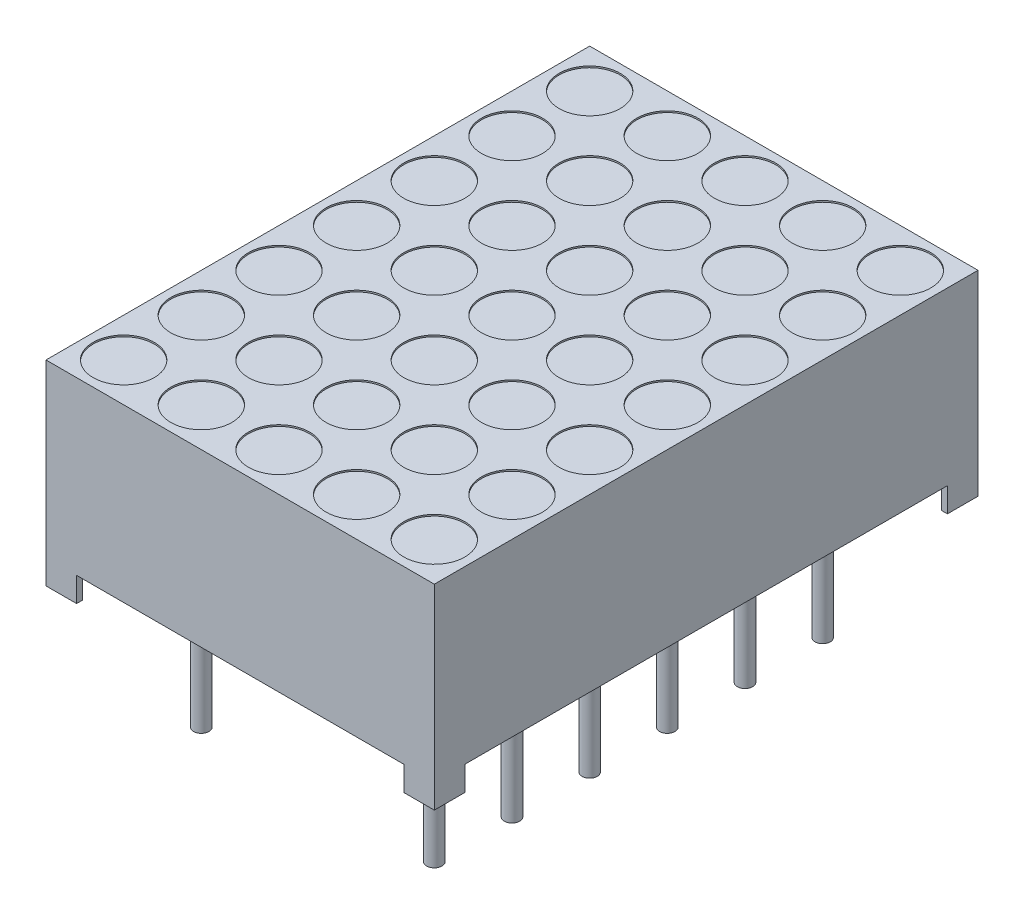
from build123d import *

# Parameters (mm, degrees)
EXTRUDE1_DEPTH     = 6.35
SKETCH3_W          = 10.7
SKETCH3_H          = 0.8
CUT_EXTRUDE1_DEPTH = 18.78
SKETCH2_R          = 1
CUT_EXTRUDE2_DEPTH = 0.05
SKETCH4_R          = 0.25
EXTRUDE2_DEPTH     = 0.8
SKETCH4_3_R        = 0.25
EXTRUDE3_DEPTH     = 4
SKETCH4_4_W        = 0.8
SKETCH4_4_H        = 0.8
CUT_EXTRUDE3_DEPTH = 0.8
SKETCH5_W          = 0.025316456
SKETCH5_H          = 0.026582278
CUT_EXTRUDE4_DEPTH = 0.01


with BuildPart() as part:
    # Sketch1 → Extrude1 (new body, symmetric)
    with BuildSketch(Plane(origin=(0, 0, 0), x_dir=(0, 0, -1), z_dir=(1, 0, 0))):
        Polygon((8.89, 3.2), (-8.89, 3.2), (6.6675, -2.4), (7.89, -2.4), (7.89, -2.840044994), (8.89, -3.2), align=None)
        Polygon((6.6675, -2.4), (-8.89, 3.2), (-8.89, -3.2), (-7.89, -3.2), (-7.89, -2.4), align=None)
        Polygon((8.89, -3.2), (7.89, -2.840044994), (7.89, -3.2), align=None)
    extrude(amount=EXTRUDE1_DEPTH, both=True)

    # Sketch3 → Cut-Extrude1 (cut, through all)
    with BuildSketch(Plane.XY.offset(8.89)):
        with Locations((0, -2.8)):
            Rectangle(SKETCH3_W, SKETCH3_H)
    extrude(amount=-CUT_EXTRUDE1_DEPTH, mode=Mode.SUBTRACT)

    # Sketch2 → Cut-Extrude2 (cut)
    with BuildSketch(Plane(origin=(0, 3.2, 0), x_dir=(-1, 0, 0), z_dir=(0, 1, 0))):
        with Locations(Location((5.08, -7.62, 0), (0, 0, 90))):  # turned: the seam where the file's is
            Circle(SKETCH2_R)
        with Locations(Location((2.54, -7.62, 0), (0, 0, 90))):  # turned: the seam where the file's is
            Circle(SKETCH2_R)
        with Locations(Location((0, -7.62, 0), (0, 0, 90))):  # turned: the seam where the file's is
            Circle(SKETCH2_R)
        with Locations(Location((-2.54, -7.62, 0), (0, 0, 90))):  # turned: the seam where the file's is
            Circle(SKETCH2_R)
        with Locations(Location((-5.08, -7.62, 0), (0, 0, 90))):  # turned: the seam where the file's is
            Circle(SKETCH2_R)
        with Locations(Location((-5.08, -5.08, 0), (0, 0, 90))):  # turned: the seam where the file's is
            Circle(SKETCH2_R)
        with Locations(Location((-2.54, -5.08, 0), (0, 0, 90))):  # turned: the seam where the file's is
            Circle(SKETCH2_R)
        with Locations(Location((0, -5.08, 0), (0, 0, 90))):  # turned: the seam where the file's is
            Circle(SKETCH2_R)
        with Locations(Location((2.54, -5.08, 0), (0, 0, 90))):  # turned: the seam where the file's is
            Circle(SKETCH2_R)
        with Locations(Location((5.08, -5.08, 0), (0, 0, 90))):  # turned: the seam where the file's is
            Circle(SKETCH2_R)
        with Locations(Location((5.08, -2.54, 0), (0, 0, 90))):  # turned: the seam where the file's is
            Circle(SKETCH2_R)
        with Locations(Location((2.54, -2.54, 0), (0, 0, 90))):  # turned: the seam where the file's is
            Circle(SKETCH2_R)
        with Locations(Location((0, -2.54, 0), (0, 0, 90))):  # turned: the seam where the file's is
            Circle(SKETCH2_R)
        with Locations(Location((-2.54, -2.54, 0), (0, 0, 90))):  # turned: the seam where the file's is
            Circle(SKETCH2_R)
        with Locations(Location((-5.08, -2.54, 0), (0, 0, 90))):  # turned: the seam where the file's is
            Circle(SKETCH2_R)
        with Locations(Location((-5.08, 0, 0), (0, 0, 90))):  # turned: the seam where the file's is
            Circle(SKETCH2_R)
        with Locations(Location((-2.54, 0, 0), (0, 0, 90))):  # turned: the seam where the file's is
            Circle(SKETCH2_R)
        with Locations(Location((0, 0, 0), (0, 0, 90))):  # turned: the seam where the file's is
            Circle(SKETCH2_R)
        with Locations(Location((2.54, 0, 0), (0, 0, 90))):  # turned: the seam where the file's is
            Circle(SKETCH2_R)
        with Locations(Location((5.08, 0, 0), (0, 0, 90))):  # turned: the seam where the file's is
            Circle(SKETCH2_R)
        with Locations(Location((5.08, 2.54, 0), (0, 0, 90))):  # turned: the seam where the file's is
            Circle(SKETCH2_R)
        with Locations(Location((2.54, 2.54, 0), (0, 0, 90))):  # turned: the seam where the file's is
            Circle(SKETCH2_R)
        with Locations(Location((0, 2.54, 0), (0, 0, 90))):  # turned: the seam where the file's is
            Circle(SKETCH2_R)
        with Locations(Location((-2.54, 2.54, 0), (0, 0, 90))):  # turned: the seam where the file's is
            Circle(SKETCH2_R)
        with Locations(Location((-5.08, 2.54, 0), (0, 0, 90))):  # turned: the seam where the file's is
            Circle(SKETCH2_R)
        with Locations(Location((-5.08, 5.08, 0), (0, 0, 90))):  # turned: the seam where the file's is
            Circle(SKETCH2_R)
        with Locations(Location((-2.54, 5.08, 0), (0, 0, 90))):  # turned: the seam where the file's is
            Circle(SKETCH2_R)
        with Locations(Location((0, 5.08, 0), (0, 0, 90))):  # turned: the seam where the file's is
            Circle(SKETCH2_R)
        with Locations(Location((2.54, 5.08, 0), (0, 0, 90))):  # turned: the seam where the file's is
            Circle(SKETCH2_R)
        with Locations(Location((5.08, 5.08, 0), (0, 0, 90))):  # turned: the seam where the file's is
            Circle(SKETCH2_R)
        with Locations(Location((5.08, 7.62, 0), (0, 0, 90))):  # turned: the seam where the file's is
            Circle(SKETCH2_R)
        with Locations(Location((2.54, 7.62, 0), (0, 0, 90))):  # turned: the seam where the file's is
            Circle(SKETCH2_R)
        with Locations(Location((0, 7.62, 0), (0, 0, 90))):  # turned: the seam where the file's is
            Circle(SKETCH2_R)
        with Locations(Location((-2.54, 7.62, 0), (0, 0, 90))):  # turned: the seam where the file's is
            Circle(SKETCH2_R)
        with Locations(Location((-5.08, 7.62, 0), (0, 0, 90))):  # turned: the seam where the file's is
            Circle(SKETCH2_R)
    extrude(amount=-CUT_EXTRUDE2_DEPTH, mode=Mode.SUBTRACT)

    # Sketch4 → Extrude2 (add)
    with BuildSketch(Plane.XZ.offset(3.2)):
        with Locations((-3.81, 6.35)):
            Circle(SKETCH4_R)
        with Locations(Location((-3.81, 3.81, 0), (0, 0, 270))):  # turned: the seam where the file's is
            Circle(SKETCH4_R)
        with Locations(Location((-3.81, 1.27, 0), (0, 0, 270))):  # turned: the seam where the file's is
            Circle(SKETCH4_R)
        with Locations(Location((-3.81, -6.35, 0), (0, 0, 270))):  # turned: the seam where the file's is
            Circle(SKETCH4_R)
        with Locations(Location((-3.81, -1.27, 0), (0, 0, 270))):  # turned: the seam where the file's is
            Circle(SKETCH4_R)
        with Locations(Location((-3.81, -3.81, 0), (0, 0, 270))):  # turned: the seam where the file's is
            Circle(SKETCH4_R)
        with Locations(Location((3.81, -3.81, 0), (0, 0, 270))):  # turned: the seam where the file's is
            Circle(SKETCH4_R)
        with Locations(Location((3.81, -1.27, 0), (0, 0, 270))):  # turned: the seam where the file's is
            Circle(SKETCH4_R)
        with Locations(Location((3.81, -6.35, 0), (0, 0, 270))):  # turned: the seam where the file's is
            Circle(SKETCH4_R)
        with Locations(Location((3.81, 1.27, 0), (0, 0, 270))):  # turned: the seam where the file's is
            Circle(SKETCH4_R)
        with Locations(Location((3.81, 3.81, 0), (0, 0, 270))):  # turned: the seam where the file's is
            Circle(SKETCH4_R)
        with Locations(Location((3.81, 6.35, 0), (0, 0, 270))):  # turned: the seam where the file's is
            Circle(SKETCH4_R)
    extrude(amount=-EXTRUDE2_DEPTH)

    # Sketch4_3 → Extrude3 (add)
    with BuildSketch(Plane.XZ.offset(3.2)):
        with Locations((-3.81, 6.35)):
            Circle(SKETCH4_3_R)
        with Locations((-3.81, 3.81)):
            Circle(SKETCH4_3_R)
        with Locations((-3.81, 1.27)):
            Circle(SKETCH4_3_R)
        with Locations((-3.81, -6.35)):
            Circle(SKETCH4_3_R)
        with Locations((-3.81, -1.27)):
            Circle(SKETCH4_3_R)
        with Locations((-3.81, -3.81)):
            Circle(SKETCH4_3_R)
        with Locations(Location((3.81, -3.81, 0), (0, 0, 180))):  # turned: the seam where the file's is
            Circle(SKETCH4_3_R)
        with Locations(Location((3.81, -1.27, 0), (0, 0, 180))):  # turned: the seam where the file's is
            Circle(SKETCH4_3_R)
        with Locations(Location((3.81, -6.35, 0), (0, 0, 180))):  # turned: the seam where the file's is
            Circle(SKETCH4_3_R)
        with Locations(Location((3.81, 1.27, 0), (0, 0, 180))):  # turned: the seam where the file's is
            Circle(SKETCH4_3_R)
        with Locations(Location((3.81, 3.81, 0), (0, 0, 180))):  # turned: the seam where the file's is
            Circle(SKETCH4_3_R)
        with Locations(Location((3.81, 6.35, 0), (0, 0, 180))):  # turned: the seam where the file's is
            Circle(SKETCH4_3_R)
    extrude(amount=EXTRUDE3_DEPTH)

    # Sketch4_4 → Cut-Extrude3 (cut)
    with BuildSketch(Plane.XZ.offset(3.2)):
        with Locations((-5.75, 8.29)):
            Rectangle(SKETCH4_4_W, SKETCH4_4_H)
        with Locations((5.75, 8.29)):
            Rectangle(SKETCH4_4_W, SKETCH4_4_H)
        with Locations((5.75, -8.29)):
            Rectangle(SKETCH4_4_W, SKETCH4_4_H)
        with Locations((-5.75, -8.29)):
            Rectangle(SKETCH4_4_W, SKETCH4_4_H)
    extrude(amount=-CUT_EXTRUDE3_DEPTH, mode=Mode.SUBTRACT)

    # Sketch5 → Cut-Extrude4 (cut)
    with BuildSketch(Plane.XZ.offset(2.4)):
        Polygon((0.765682289, 6.275316456), (0.789139567, 6.35), (0.813882447, 6.35), (0.830298586, 6.299663766), (0.845824694, 6.35), (0.871556497, 6.35), (0.894796213, 6.275316456), (0.869618206, 6.275316456), (0.856623744, 6.326799842), (0.840207605, 6.275316456), (0.818708396, 6.275316456), (0.802391149, 6.326799842), (0.789574694, 6.275316456), align=None)
        Polygon((0.631505073, 6.275316456), (0.654962352, 6.35), (0.679705232, 6.35), (0.696121371, 6.299663766), (0.711647478, 6.35), (0.737379282, 6.35), (0.760618997, 6.275316456), (0.735440991, 6.275316456), (0.722446529, 6.326799842), (0.70603039, 6.275316456), (0.684531181, 6.275316456), (0.668213934, 6.326799842), (0.655397478, 6.275316456), align=None)
        Polygon((0.497327858, 6.275316456), (0.520785137, 6.35), (0.545528016, 6.35), (0.561944156, 6.299663766), (0.577470263, 6.35), (0.603202067, 6.35), (0.626441782, 6.275316456), (0.601263776, 6.275316456), (0.588269314, 6.326799842), (0.571853175, 6.275316456), (0.550353966, 6.275316456), (0.534036719, 6.326799842), (0.521220263, 6.275316456), align=None)
        with Locations((0.469479757, 6.336708861)):
            Rectangle(SKETCH5_W, SKETCH5_H)
        with BuildLine():
            add(Edge.make_bspline(
                [(0.353024061, 6.318829114), (0.353060589, 6.320051228), (0.353132318, 6.322451052), (0.35374148, 6.325959018), (0.354737004, 6.329282301), (0.356101342, 6.332445017), (0.35791533, 6.335400383), (0.360070344, 6.33821895), (0.362682258, 6.340802912), (0.365619294, 6.343241673), (0.368917222, 6.345424068), (0.372519844, 6.347324206), (0.376390163, 6.348948925), (0.380544184, 6.350280615), (0.384989762, 6.351271382), (0.389707539, 6.351994699), (0.394700887, 6.352468207), (0.398124475, 6.352510148), (0.399879282, 6.352531646)],
                knots=[0, 0, 0, 0, 0.907421153, 1.781872267, 2.635683434, 3.480115191, 4.332689235, 5.205575272, 6.109500117, 7.055808355, 8.037942167, 9.041423561, 10.07750834, 11.152467461, 12.277657752, 13.45734338, 14.696726425, 16, 16, 16, 16], degree=3))
            add(Edge.make_bspline(
                [(0.399879282, 6.352531646), (0.401897267, 6.352504381), (0.405805453, 6.352451577), (0.411473021, 6.352066204), (0.416736487, 6.351378254), (0.421634235, 6.350421674), (0.426238535, 6.349218389), (0.43067188, 6.347927745), (0.434953172, 6.346463164), (0.437726264, 6.345363028), (0.43910001, 6.344818038)],
                knots=[0, 0, 0, 0, 1.203182053, 2.33017619, 3.384818652, 4.366208123, 5.30340534, 6.221361684, 7.118890722, 8, 8, 8, 8], degree=3))
            Line((0.43910001, 6.344818038), (0.43910001, 6.320886076))
            Line((0.43910001, 6.320886076), (0.436251909, 6.320886076))
            add(Edge.make_bspline(
                [(0.436251909, 6.320886076), (0.434886345, 6.321967039), (0.432163236, 6.324122618), (0.427736278, 6.326890972), (0.423077266, 6.329263982), (0.418238872, 6.331246605), (0.413337504, 6.332822219), (0.408468436, 6.333949125), (0.403699453, 6.334688489), (0.400541132, 6.33477005), (0.398989251, 6.334810127)],
                knots=[0, 0, 0, 0, 1.030738938, 2.055426519, 3.085610749, 4.123842265, 5.148648843, 6.130724483, 7.081507926, 8, 8, 8, 8], degree=3))
            add(Edge.make_bspline(
                [(0.398989251, 6.334810127), (0.398560504, 6.334808826), (0.397642592, 6.334806041), (0.396173444, 6.334684726), (0.3945171, 6.334556882), (0.392736362, 6.334360768), (0.390949157, 6.334129623), (0.38928891, 6.333783156), (0.387788148, 6.333414005), (0.386881479, 6.333046739), (0.386449694, 6.332871835)],
                knots=[0, 0, 0, 0, 0.806537132, 1.726733348, 2.77251655, 3.932999672, 5.098049949, 6.161349231, 7.124375527, 8, 8, 8, 8], degree=3))
            add(Edge.make_bspline(
                [(0.386449694, 6.332871835), (0.385970207, 6.3326436), (0.385027915, 6.332195068), (0.383725384, 6.331381158), (0.382554899, 6.330486413), (0.381494197, 6.32952468), (0.380631801, 6.328361692), (0.38001064, 6.326962421), (0.37966607, 6.325313128), (0.379626998, 6.324137966), (0.379606339, 6.323516614)],
                knots=[0, 0, 0, 0, 1.02474257, 2.013837243, 2.958431669, 3.867978675, 4.769292696, 5.732237074, 6.800947934, 8, 8, 8, 8], degree=3))
            add(Edge.make_bspline(
                [(0.379606339, 6.323516614), (0.3796378, 6.322970748), (0.379699663, 6.321897414), (0.380281169, 6.320368984), (0.381165216, 6.318948848), (0.382444631, 6.317683512), (0.384058309, 6.3165574), (0.385989296, 6.315546637), (0.388263147, 6.314710879), (0.38990036, 6.314273007), (0.390761402, 6.314042722)],
                knots=[0, 0, 0, 0, 0.825427492, 1.623033598, 2.45033906, 3.348940377, 4.33183287, 5.428402891, 6.647546779, 8, 8, 8, 8], degree=3))
            add(Edge.make_bspline(
                [(0.390761402, 6.314042722), (0.392730643, 6.313597517), (0.396765855, 6.312685239), (0.402905668, 6.311497785), (0.409044371, 6.310271914), (0.413000627, 6.309057599), (0.414930706, 6.30846519)],
                knots=[0, 0, 0, 0, 0.976118991, 2.000185432, 3.024380873, 4, 4, 4, 4], degree=3))
            add(Edge.make_bspline(
                [(0.414930706, 6.30846519), (0.415968859, 6.308111467), (0.417989721, 6.307422913), (0.420888913, 6.306270264), (0.42353216, 6.30496513), (0.4259897, 6.303643092), (0.428182364, 6.302163034), (0.430176997, 6.300630275), (0.431929658, 6.29897747), (0.433456096, 6.297227978), (0.434798962, 6.295391616), (0.435952371, 6.293444475), (0.436913394, 6.291378025), (0.437736786, 6.289222628), (0.438348013, 6.286948093), (0.438770449, 6.284571676), (0.439068512, 6.282088189), (0.439089368, 6.280393854), (0.43910001, 6.279529272)],
                knots=[0, 0, 0, 0, 1.287376879, 2.505999703, 3.65855109, 4.746193839, 5.778582289, 6.760029101, 7.696159662, 8.601061861, 9.48181646, 10.363080883, 11.252765705, 12.153987336, 13.068239035, 14.012364187, 14.985753787, 16, 16, 16, 16], degree=3))
            add(Edge.make_bspline(
                [(0.43910001, 6.279529272), (0.43906271, 6.278373126), (0.438989303, 6.276097851), (0.438387853, 6.272768828), (0.437361342, 6.26962001), (0.435974983, 6.266616854), (0.43414749, 6.26380259), (0.431955367, 6.261125104), (0.429345057, 6.258632608), (0.42635973, 6.256333971), (0.423072882, 6.254255166), (0.419538877, 6.252418458), (0.415760026, 6.250912011), (0.411780141, 6.24963078), (0.407560748, 6.248678384), (0.403123778, 6.247958807), (0.398449915, 6.247545806), (0.395258504, 6.247494531), (0.393629282, 6.247468354)],
                knots=[0, 0, 0, 0, 0.894901293, 1.761149761, 2.608783409, 3.453876344, 4.314933854, 5.200038827, 6.12799933, 7.103249695, 8.113098521, 9.136064399, 10.182719798, 11.259667356, 12.370545059, 13.528828137, 14.738461593, 16, 16, 16, 16], degree=3))
            add(Edge.make_bspline(
                [(0.393629282, 6.247468354), (0.391960631, 6.247490747), (0.388626157, 6.247535495), (0.383644184, 6.247910464), (0.378686769, 6.248476966), (0.373815205, 6.24927642), (0.369132698, 6.250294076), (0.364716084, 6.251380034), (0.360637114, 6.252620424), (0.358063389, 6.253574469), (0.356821529, 6.25403481)],
                knots=[0, 0, 0, 0, 1.065379838, 2.128953261, 3.188461447, 4.250817766, 5.279613205, 6.247547721, 7.154416075, 8, 8, 8, 8], degree=3))
            Line((0.356821529, 6.25403481), (0.356821529, 6.276582278))
            Line((0.356821529, 6.276582278), (0.359649852, 6.276582278))
            add(Edge.make_bspline(
                [(0.359649852, 6.276582278), (0.360722811, 6.275782075), (0.362917042, 6.274145637), (0.366575794, 6.27205966), (0.370539855, 6.270110146), (0.374804756, 6.268388353), (0.379277297, 6.266967752), (0.383854843, 6.265938708), (0.388481908, 6.265299585), (0.391583499, 6.265226452), (0.39313482, 6.265189873)],
                knots=[0, 0, 0, 0, 0.89224925, 1.824673196, 2.804309561, 3.838364047, 4.890042674, 5.931526337, 6.965412421, 8, 8, 8, 8], degree=3))
            add(Edge.make_bspline(
                [(0.39313482, 6.265189873), (0.39423012, 6.265214083), (0.396419865, 6.265262484), (0.399694273, 6.265611738), (0.402929064, 6.266283479), (0.404971963, 6.267097816), (0.405990833, 6.267503956)],
                knots=[0, 0, 0, 0, 0.998993879, 1.997209027, 3.00113285, 4, 4, 4, 4], degree=3))
            add(Edge.make_bspline(
                [(0.405990833, 6.267503956), (0.406424312, 6.267705438), (0.407290981, 6.26810827), (0.408497985, 6.268880595), (0.409601289, 6.269810313), (0.410602294, 6.270862707), (0.41145035, 6.272032042), (0.41208801, 6.273301801), (0.412448829, 6.27466378), (0.412494666, 6.275597948), (0.412517732, 6.276068038)],
                knots=[0, 0, 0, 0, 1.005454979, 2.010239304, 3.005296729, 4.036100111, 5.060531193, 6.034954812, 7.011155677, 8, 8, 8, 8], degree=3))
            add(Edge.make_bspline(
                [(0.412517732, 6.276068038), (0.412482937, 6.276705969), (0.412416448, 6.277924997), (0.411816451, 6.279638693), (0.410818782, 6.281101805), (0.409665683, 6.282094798), (0.408548704, 6.282793558), (0.407508187, 6.283298798), (0.406308736, 6.283812221), (0.404931287, 6.284301418), (0.403396152, 6.284795464), (0.401687229, 6.285270134), (0.399804622, 6.285719693), (0.398488731, 6.286005845), (0.397802542, 6.286155063)],
                knots=[0, 0, 0, 0, 1.174343879, 2.244064321, 3.303704314, 4.407076671, 5.02483983, 5.732197225, 6.53898402, 7.431906431, 8.428480183, 9.514816237, 10.704066255, 12, 12, 12, 12], degree=3))
            add(Edge.make_bspline(
                [(0.397802542, 6.286155063), (0.395969917, 6.286531783), (0.392369214, 6.287271955), (0.386964139, 6.288366252), (0.381471085, 6.289678769), (0.377800535, 6.290807982), (0.375887985, 6.291396361)],
                knots=[0, 0, 0, 0, 0.995788186, 1.956503735, 2.935230479, 4, 4, 4, 4], degree=3))
            add(Edge.make_bspline(
                [(0.375887985, 6.291396361), (0.374941428, 6.291715602), (0.373089811, 6.29234009), (0.370449213, 6.293426408), (0.368002039, 6.294600265), (0.365735405, 6.295842235), (0.36366004, 6.297184668), (0.36177375, 6.298610001), (0.360075793, 6.300114784), (0.358587044, 6.301730504), (0.357258287, 6.303440852), (0.356145943, 6.305291465), (0.355150358, 6.307234994), (0.354397203, 6.309328437), (0.353772693, 6.311526965), (0.353350951, 6.313858899), (0.353056588, 6.316303117), (0.353035024, 6.317977716), (0.353024061, 6.318829114)],
                knots=[0, 0, 0, 0, 1.237326419, 2.420410185, 3.534642089, 4.598489486, 5.620241961, 6.59385002, 7.525152549, 8.426792174, 9.312230456, 10.203151844, 11.098070343, 12.012931196, 12.954244379, 13.926618287, 14.945853925, 16, 16, 16, 16], degree=3))
        make_face()
        with BuildLine():
            Line((0.260618997, 6.35), (0.28466963, 6.35))
            Line((0.28466963, 6.35), (0.28466963, 6.342167722))
            add(Edge.make_bspline(
                [(0.28466963, 6.342167722), (0.285762824, 6.342976516), (0.287870486, 6.344535861), (0.291045045, 6.346612923), (0.294063345, 6.348397345), (0.296993697, 6.349920462), (0.299999974, 6.351132633), (0.303238108, 6.351951014), (0.306739704, 6.352453738), (0.309166774, 6.352505099), (0.310421213, 6.352531646)],
                knots=[0, 0, 0, 0, 1.150945962, 2.219006967, 3.209666795, 4.118194914, 5.012574058, 5.946577101, 6.93868214, 8, 8, 8, 8], degree=3))
            add(Edge.make_bspline(
                [(0.310421213, 6.352531646), (0.311437488, 6.352508698), (0.313416468, 6.352464012), (0.316294768, 6.352122291), (0.318996734, 6.351573882), (0.321525571, 6.350805475), (0.323875271, 6.349802444), (0.326018951, 6.34853081), (0.328021528, 6.347098096), (0.329803475, 6.34539173), (0.331419021, 6.343493812), (0.332801592, 6.341361403), (0.333979297, 6.339028463), (0.334920397, 6.336476613), (0.335675485, 6.333718309), (0.336199418, 6.330739061), (0.33652001, 6.327551934), (0.33655195, 6.325356803), (0.336568364, 6.324228639)],
                knots=[0, 0, 0, 0, 1.108959949, 2.159465255, 3.158589008, 4.114545495, 5.039534357, 5.93921201, 6.830099133, 7.720870013, 8.624681761, 9.544731627, 10.487599671, 11.471264588, 12.508152322, 13.604835107, 14.769030043, 16, 16, 16, 16], degree=3))
            Line((0.336568364, 6.324228639), (0.336568364, 6.275316456))
            Line((0.336568364, 6.275316456), (0.312517732, 6.275316456))
            Line((0.312517732, 6.275316456), (0.312517732, 6.31289557))
            add(Edge.make_bspline(
                [(0.312517732, 6.31289557), (0.312516096, 6.313812041), (0.312512965, 6.315566256), (0.312430627, 6.318072063), (0.312309726, 6.320340235), (0.312171021, 6.322382264), (0.311918005, 6.324229015), (0.311540296, 6.325895176), (0.31106947, 6.327414778), (0.310605151, 6.328321479), (0.310381656, 6.328757911)],
                knots=[0, 0, 0, 0, 1.361401701, 2.605856924, 3.723918663, 4.735739235, 5.645738665, 6.489217889, 7.27279937, 8, 8, 8, 8], degree=3))
            add(Edge.make_bspline(
                [(0.310381656, 6.328757911), (0.310151647, 6.329156617), (0.30969947, 6.329940438), (0.308779206, 6.33094675), (0.307700363, 6.3317905), (0.30642316, 6.332448601), (0.304933593, 6.332939104), (0.303212734, 6.333319675), (0.301220993, 6.333491553), (0.299813525, 6.333526043), (0.299068364, 6.333544304)],
                knots=[0, 0, 0, 0, 0.849004071, 1.669068917, 2.503060811, 3.370079215, 4.310762265, 5.396376419, 6.621555549, 8, 8, 8, 8], degree=3))
            add(Edge.make_bspline(
                [(0.299068364, 6.333544304), (0.298527422, 6.333524465), (0.297416005, 6.333483703), (0.295698553, 6.333292162), (0.293909293, 6.332893004), (0.291390624, 6.332248059), (0.288225414, 6.331054204), (0.28586588, 6.329701058), (0.28466963, 6.329015032)],
                knots=[0, 0, 0, 0, 0.638062719, 1.310959128, 2.033463623, 2.796942592, 4.376095945, 6, 6, 6, 6], degree=3))
            Line((0.28466963, 6.329015032), (0.28466963, 6.275316456))
            Line((0.28466963, 6.275316456), (0.260618997, 6.275316456))
            Line((0.260618997, 6.275316456), (0.260618997, 6.35))
        make_face()
        with BuildLine():
            Line((0.163150643, 6.35), (0.187201276, 6.35))
            Line((0.187201276, 6.35), (0.187201276, 6.312420886))
            add(Edge.make_bspline(
                [(0.187201276, 6.312420886), (0.187226282, 6.310890897), (0.187276254, 6.307833405), (0.187552805, 6.304070311), (0.187937291, 6.301228771), (0.188304831, 6.299397183), (0.188736702, 6.297849066), (0.189148964, 6.296963305), (0.189337352, 6.296558544)],
                knots=[0, 0, 0, 0, 1.709111167, 3.415443484, 4.21113913, 4.910175115, 5.501990373, 6, 6, 6, 6], degree=3))
            add(Edge.make_bspline(
                [(0.189337352, 6.296558544), (0.189581813, 6.296160481), (0.190061113, 6.295380023), (0.190998463, 6.294367147), (0.192092247, 6.293537778), (0.193363423, 6.292858311), (0.194851532, 6.292379123), (0.196575449, 6.292026369), (0.198555634, 6.291815815), (0.199964462, 6.291787262), (0.200709978, 6.291772152)],
                knots=[0, 0, 0, 0, 0.860202684, 1.686548532, 2.528236983, 3.382486038, 4.33249885, 5.401154041, 6.624757403, 8, 8, 8, 8], degree=3))
            add(Edge.make_bspline(
                [(0.200709978, 6.291772152), (0.201840867, 6.291832252), (0.204148563, 6.291954894), (0.207023873, 6.29262156), (0.209341211, 6.293481524), (0.211198927, 6.29423196), (0.213106649, 6.295206061), (0.214386192, 6.295927502), (0.215049377, 6.296301424)],
                knots=[0, 0, 0, 0, 1.33818541, 2.730705359, 3.468371228, 4.262126284, 5.099261778, 6, 6, 6, 6], degree=3))
            Line((0.215049377, 6.296301424), (0.215049377, 6.35))
            Line((0.215049377, 6.35), (0.23910001, 6.35))
            Line((0.23910001, 6.35), (0.23910001, 6.275316456))
            Line((0.23910001, 6.275316456), (0.215049377, 6.275316456))
            Line((0.215049377, 6.275316456), (0.215049377, 6.283148734))
            add(Edge.make_bspline(
                [(0.215049377, 6.283148734), (0.213991971, 6.282342583), (0.211933666, 6.28077336), (0.208754428, 6.27873294), (0.20567053, 6.276934171), (0.20261752, 6.275421354), (0.199502566, 6.274214579), (0.196239807, 6.27340359), (0.192823401, 6.272859787), (0.190486686, 6.272810094), (0.189297795, 6.27278481)],
                knots=[0, 0, 0, 0, 1.126119141, 2.192057864, 3.198061997, 4.149848529, 5.076251285, 6.021887753, 6.99356175, 8, 8, 8, 8], degree=3))
            add(Edge.make_bspline(
                [(0.189297795, 6.27278481), (0.18830153, 6.27281021), (0.186356643, 6.272859797), (0.183521794, 6.273169348), (0.180850687, 6.273720571), (0.178357303, 6.274516428), (0.176021617, 6.275507787), (0.173847945, 6.276711766), (0.171862096, 6.278175048), (0.170033944, 6.279834986), (0.168394844, 6.281726284), (0.166997934, 6.283855662), (0.165793572, 6.286192582), (0.164844307, 6.288755219), (0.164052983, 6.291521491), (0.163548219, 6.294520121), (0.163190566, 6.297730007), (0.163164217, 6.299946157), (0.163150643, 6.301087816)],
                knots=[0, 0, 0, 0, 1.08828964, 2.12453497, 3.110382522, 4.062402335, 4.978696626, 5.878225494, 6.769849763, 7.667011675, 8.57076823, 9.495541561, 10.442454184, 11.436213583, 12.475881554, 13.580560132, 14.753614518, 16, 16, 16, 16], degree=3))
            Line((0.163150643, 6.301087816), (0.163150643, 6.35))
        make_face()
        Polygon((0.068213934, 6.35), (0.140365833, 6.35), (0.140365833, 6.25), (0.115049377, 6.25), (0.115049377, 6.331012658), (0.068213934, 6.331012658), align=None)
        Polygon((-0.019127838, 6.35), (0.053024061, 6.35), (0.053024061, 6.25), (-0.019127838, 6.25), (-0.019127838, 6.268987342), (0.027707605, 6.268987342), (0.027707605, 6.286708861), (-0.01533037, 6.286708861), (-0.01533037, 6.305696203), (0.027707605, 6.305696203), (0.027707605, 6.331012658), (-0.019127838, 6.331012658), align=None)
        with BuildLine():
            add(Edge.make_bspline(
                [(-0.135583534, 6.300098892), (-0.135564219, 6.301246581), (-0.135525967, 6.303519467), (-0.135230776, 6.306884274), (-0.13470475, 6.310149949), (-0.134025569, 6.313334198), (-0.133103063, 6.316413126), (-0.132021349, 6.319420703), (-0.130711703, 6.322326196), (-0.129206851, 6.325127631), (-0.127557379, 6.327799734), (-0.12578263, 6.330319942), (-0.12393685, 6.33270316), (-0.121947538, 6.334898054), (-0.119868356, 6.336940074), (-0.117692828, 6.338830888), (-0.115387763, 6.340534319), (-0.113780601, 6.341557203), (-0.11297673, 6.342068829)],
                knots=[0, 0, 0, 0, 1.105570398, 2.18947457, 3.250358341, 4.290584537, 5.323553275, 6.344225964, 7.367641686, 8.3905646, 9.405808457, 10.390761353, 11.358902336, 12.307789878, 13.241960776, 14.165076779, 15.082208636, 16, 16, 16, 16], degree=3))
            add(Edge.make_bspline(
                [(-0.11297673, 6.342068829), (-0.111737543, 6.34278115), (-0.109252846, 6.344209427), (-0.105268388, 6.345875266), (-0.101146779, 6.347289489), (-0.096787599, 6.34830293), (-0.092148877, 6.349072765), (-0.087144066, 6.349620936), (-0.08173716, 6.349926439), (-0.078002167, 6.349974921), (-0.076070085, 6.35)],
                knots=[0, 0, 0, 0, 0.896321744, 1.797216976, 2.705381885, 3.628777036, 4.602292017, 5.655629376, 6.787275635, 8, 8, 8, 8], degree=3))
            Line((-0.076070085, 6.35), (-0.040646825, 6.35))
            Line((-0.040646825, 6.35), (-0.040646825, 6.25))
            Line((-0.040646825, 6.25), (-0.077078787, 6.25))
            add(Edge.make_bspline(
                [(-0.077078787, 6.25), (-0.079057484, 6.25001681), (-0.082874143, 6.250049235), (-0.08839146, 6.250464162), (-0.093493798, 6.251069925), (-0.098183378, 6.251964111), (-0.102485828, 6.253078692), (-0.106403119, 6.254467223), (-0.110019352, 6.25595984), (-0.112197887, 6.257234394), (-0.113253629, 6.257852057)],
                knots=[0, 0, 0, 0, 1.267083275, 2.444046388, 3.541868212, 4.55639609, 5.499737919, 6.385160515, 7.217431253, 8, 8, 8, 8], degree=3))
            add(Edge.make_bspline(
                [(-0.113253629, 6.257852057), (-0.114104583, 6.258388598), (-0.115796707, 6.259455511), (-0.118197922, 6.261237363), (-0.120427349, 6.26319344), (-0.122555852, 6.265245259), (-0.124535669, 6.267448146), (-0.126378869, 6.269786853), (-0.128082686, 6.272264947), (-0.12964065, 6.274874416), (-0.131061465, 6.277604468), (-0.132250771, 6.280477527), (-0.13330012, 6.283456057), (-0.134105656, 6.286565019), (-0.13480357, 6.289772856), (-0.135238305, 6.2931142), (-0.135524915, 6.296566688), (-0.13556383, 6.298911578), (-0.135583534, 6.300098892)],
                knots=[0, 0, 0, 0, 0.964065863, 1.917049184, 2.86229036, 3.805247319, 4.749389377, 5.698846072, 6.657678277, 7.629829384, 8.610569287, 9.604676042, 10.607940105, 11.6349849, 12.681042988, 13.752616828, 14.862056989, 16, 16, 16, 16], degree=3))
        make_face()
        with BuildLine():
            add(Edge.make_bspline(
                [(-0.109001256, 6.299940665), (-0.108957953, 6.298362234), (-0.108874341, 6.295314435), (-0.108168946, 6.290918791), (-0.107029696, 6.286875841), (-0.105692004, 6.283763425), (-0.104354612, 6.281490107), (-0.103227089, 6.279891837), (-0.101977423, 6.278377637), (-0.100586813, 6.276968797), (-0.099051629, 6.275661761), (-0.09739037, 6.27443285), (-0.095590329, 6.273304205), (-0.094317298, 6.272644199), (-0.093672933, 6.272310127)],
                knots=[0, 0, 0, 0, 1.694683197, 3.272273219, 4.767406206, 6.197615014, 6.895990032, 7.597410435, 8.296503208, 9.002591366, 9.720792421, 10.460154445, 11.220583224, 12, 12, 12, 12], degree=3))
            add(Edge.make_bspline(
                [(-0.093672933, 6.272310127), (-0.092997998, 6.272003612), (-0.09166023, 6.271396079), (-0.089589954, 6.270661993), (-0.087497253, 6.270099666), (-0.085303025, 6.269627243), (-0.082826266, 6.269350107), (-0.079903774, 6.269137431), (-0.076447101, 6.269000503), (-0.073960506, 6.268991932), (-0.072628629, 6.268987342)],
                knots=[0, 0, 0, 0, 0.826913061, 1.638999358, 2.447478739, 3.243919028, 4.140906711, 5.225381046, 6.513851968, 8, 8, 8, 8], degree=3))
            Line((-0.072628629, 6.268987342), (-0.065963281, 6.268987342))
            Line((-0.065963281, 6.268987342), (-0.065963281, 6.331012658))
            Line((-0.065963281, 6.331012658), (-0.072628629, 6.331012658))
            add(Edge.make_bspline(
                [(-0.072628629, 6.331012658), (-0.07338682, 6.331007613), (-0.074850556, 6.330997872), (-0.076967009, 6.330958769), (-0.078931771, 6.330898452), (-0.080739122, 6.33082661), (-0.082395258, 6.330711707), (-0.083883092, 6.33054311), (-0.085225442, 6.330398723), (-0.086793077, 6.330131603), (-0.088646226, 6.329715148), (-0.090807491, 6.329037056), (-0.092948024, 6.328186637), (-0.094336598, 6.327501673), (-0.095037648, 6.327155854)],
                knots=[0, 0, 0, 0, 1.186775798, 2.291144404, 3.313233901, 4.263515562, 5.122260739, 5.910868134, 6.60717912, 7.234883681, 8.398964994, 9.577230746, 10.776813768, 12, 12, 12, 12], degree=3))
            add(Edge.make_bspline(
                [(-0.095037648, 6.327155854), (-0.095621362, 6.326812378), (-0.096769299, 6.326136894), (-0.098413444, 6.325031032), (-0.099900183, 6.323796032), (-0.101306245, 6.322512934), (-0.102559111, 6.32112248), (-0.103732404, 6.319672), (-0.10474266, 6.318109607), (-0.105987655, 6.315916078), (-0.107207387, 6.312882708), (-0.108248147, 6.308916165), (-0.108884662, 6.304556155), (-0.108961396, 6.301518573), (-0.109001256, 6.299940665)],
                knots=[0, 0, 0, 0, 0.755109416, 1.485004392, 2.205961541, 2.908125208, 3.605307969, 4.290649036, 4.985852759, 5.676964147, 7.100721462, 8.614478074, 10.241350405, 12, 12, 12, 12], degree=3))
        make_face(mode=Mode.SUBTRACT)
        with Locations((-0.167229104, 6.336708861)):
            Rectangle(SKETCH5_W, SKETCH5_H)
        with BuildLine():
            add(Edge.make_bspline(
                [(-0.241873091, 6.352531646), (-0.240282986, 6.352509819), (-0.237161863, 6.352466978), (-0.232590419, 6.351990276), (-0.228225616, 6.351271809), (-0.224077998, 6.350253637), (-0.220171436, 6.348897295), (-0.216490383, 6.34727928), (-0.213101021, 6.345261474), (-0.211037291, 6.343684533), (-0.210009958, 6.342899525)],
                knots=[0, 0, 0, 0, 1.123606455, 2.205459211, 3.245124445, 4.248821949, 5.220056174, 6.165006393, 7.086533249, 8, 8, 8, 8], degree=3))
            add(Edge.make_bspline(
                [(-0.210009958, 6.342899525), (-0.209058211, 6.342044751), (-0.207158396, 6.340338508), (-0.204692463, 6.337367081), (-0.202569378, 6.334084037), (-0.200783825, 6.330481815), (-0.199352901, 6.326565086), (-0.198329768, 6.322320424), (-0.197710522, 6.317759643), (-0.197643357, 6.31461171), (-0.197608851, 6.312994462)],
                knots=[0, 0, 0, 0, 0.916457077, 1.82937027, 2.759194969, 3.714948755, 4.706655623, 5.743329475, 6.840637961, 8, 8, 8, 8], degree=3))
            add(Edge.make_bspline(
                [(-0.197608851, 6.312994462), (-0.197647611, 6.311291235), (-0.197722734, 6.307990155), (-0.198386494, 6.303217967), (-0.199456106, 6.298800287), (-0.200993664, 6.294748378), (-0.202924106, 6.291055187), (-0.205188599, 6.287683352), (-0.207809124, 6.284640428), (-0.209816263, 6.282894988), (-0.210820876, 6.282021361)],
                knots=[0, 0, 0, 0, 1.171797512, 2.271099083, 3.308930235, 4.294129479, 5.24602549, 6.17106565, 7.084581485, 8, 8, 8, 8], degree=3))
            add(Edge.make_bspline(
                [(-0.210820876, 6.282021361), (-0.21184679, 6.281252899), (-0.213911008, 6.279706695), (-0.217313852, 6.277804084), (-0.220941543, 6.27621589), (-0.224763278, 6.274939171), (-0.228738264, 6.273984554), (-0.232801818, 6.273291888), (-0.236945619, 6.272863206), (-0.239736, 6.272811068), (-0.241141287, 6.27278481)],
                knots=[0, 0, 0, 0, 0.952046378, 1.915591786, 2.889970712, 3.892742799, 4.906722985, 5.925995921, 6.955492795, 8, 8, 8, 8], degree=3))
            add(Edge.make_bspline(
                [(-0.241141287, 6.27278481), (-0.242388092, 6.272801208), (-0.244839732, 6.272833451), (-0.248438572, 6.273164054), (-0.251896531, 6.273665992), (-0.255203449, 6.274404564), (-0.258370446, 6.275326181), (-0.261424585, 6.276358243), (-0.264383818, 6.277493474), (-0.266284462, 6.278377751), (-0.267229104, 6.278817247)],
                knots=[0, 0, 0, 0, 1.107549047, 2.177816721, 3.208424937, 4.210433793, 5.185680559, 6.13785309, 7.074491882, 8, 8, 8, 8], degree=3))
            Line((-0.267229104, 6.278817247), (-0.267229104, 6.299367089))
            Line((-0.267229104, 6.299367089), (-0.263886541, 6.299367089))
            add(Edge.make_bspline(
                [(-0.263886541, 6.299367089), (-0.263385963, 6.298951202), (-0.262300938, 6.29804975), (-0.260534106, 6.296603162), (-0.258363787, 6.295102872), (-0.256716757, 6.294208247), (-0.255836699, 6.293730222)],
                knots=[0, 0, 0, 0, 0.792743043, 1.718305972, 2.780820752, 4, 4, 4, 4], degree=3))
            add(Edge.make_bspline(
                [(-0.255836699, 6.293730222), (-0.254907763, 6.293291583), (-0.253001855, 6.292391623), (-0.250458647, 6.291514235), (-0.248255467, 6.290988866), (-0.246441807, 6.290723301), (-0.24450751, 6.290536442), (-0.243172364, 6.290516551), (-0.242486224, 6.290506329)],
                knots=[0, 0, 0, 0, 1.332360773, 2.733622135, 3.480580446, 4.268165618, 5.10999921, 6, 6, 6, 6], degree=3))
            add(Edge.make_bspline(
                [(-0.242486224, 6.290506329), (-0.241720585, 6.29052566), (-0.240236813, 6.290563122), (-0.238076445, 6.29084317), (-0.236051828, 6.291311262), (-0.23416379, 6.291989206), (-0.232409958, 6.292840972), (-0.230789935, 6.293882418), (-0.229296502, 6.295105689), (-0.227977561, 6.296547321), (-0.226784747, 6.298127061), (-0.22576557, 6.299861229), (-0.224853107, 6.301707813), (-0.224158171, 6.303712266), (-0.223598432, 6.305841041), (-0.223209503, 6.308104161), (-0.222967544, 6.310503671), (-0.222939627, 6.312149979), (-0.222925306, 6.312994462)],
                knots=[0, 0, 0, 0, 1.087372478, 2.107277257, 3.088614887, 4.033572876, 4.950837204, 5.852283781, 6.763600506, 7.684681617, 8.621202104, 9.570420019, 10.537986648, 11.542161979, 12.577980734, 13.661919757, 14.800668594, 16, 16, 16, 16], degree=3))
            add(Edge.make_bspline(
                [(-0.222925306, 6.312994462), (-0.222940081, 6.313858618), (-0.222968787, 6.315537631), (-0.223202301, 6.317979242), (-0.223618192, 6.320260673), (-0.22418944, 6.322385993), (-0.224913788, 6.324352011), (-0.225818905, 6.326149408), (-0.226855262, 6.327806215), (-0.22809982, 6.329268827), (-0.229463703, 6.330585149), (-0.230978595, 6.331721283), (-0.232637834, 6.332669428), (-0.234420015, 6.333473891), (-0.236353056, 6.334052289), (-0.238409592, 6.334488981), (-0.240599147, 6.334777538), (-0.242109501, 6.334799101), (-0.242881794, 6.334810127)],
                knots=[0, 0, 0, 0, 1.230336593, 2.390482092, 3.487897344, 4.52859895, 5.520747884, 6.465347575, 7.38981449, 8.296085817, 9.192433006, 10.084246191, 10.984321635, 11.908883871, 12.862027947, 13.850751296, 14.901019963, 16, 16, 16, 16], degree=3))
            add(Edge.make_bspline(
                [(-0.242881794, 6.334810127), (-0.243607559, 6.334801377), (-0.24502241, 6.33478432), (-0.24708941, 6.334574766), (-0.249046916, 6.334267994), (-0.250880057, 6.333828041), (-0.25258279, 6.33331549), (-0.254139124, 6.332742545), (-0.2555521, 6.332139419), (-0.25641339, 6.331671663), (-0.256825623, 6.331447785)],
                knots=[0, 0, 0, 0, 1.201052708, 2.34140671, 3.435973211, 4.479046096, 5.459661032, 6.378175262, 7.223757638, 8, 8, 8, 8], degree=3))
            add(Edge.make_bspline(
                [(-0.256825623, 6.331447785), (-0.257525829, 6.33101789), (-0.258880395, 6.330186248), (-0.260719123, 6.328784682), (-0.262363992, 6.327370422), (-0.263388504, 6.326414205), (-0.263886541, 6.325949367)],
                knots=[0, 0, 0, 0, 1.098601379, 2.125273733, 3.088655601, 4, 4, 4, 4], degree=3))
            Line((-0.263886541, 6.325949367), (-0.267229104, 6.325949367))
            Line((-0.267229104, 6.325949367), (-0.267229104, 6.346657437))
            add(Edge.make_bspline(
                [(-0.267229104, 6.346657437), (-0.266283714, 6.347094931), (-0.264392707, 6.347970024), (-0.261478128, 6.349123896), (-0.258490155, 6.350092057), (-0.255441782, 6.350995137), (-0.252269699, 6.351683499), (-0.248946669, 6.352176622), (-0.24546517, 6.352477534), (-0.243086781, 6.352513362), (-0.241873091, 6.352531646)],
                knots=[0, 0, 0, 0, 0.952012952, 1.904254716, 2.862729541, 3.822037426, 4.808956931, 5.82647221, 6.890850784, 8, 8, 8, 8], degree=3))
        make_face()
        with BuildLine():
            add(Edge.make_bspline(
                [(-0.359634167, 6.312697785), (-0.359609472, 6.314202691), (-0.359561334, 6.317136157), (-0.359022017, 6.321407948), (-0.358209237, 6.325443946), (-0.357036706, 6.329231154), (-0.355556313, 6.332788429), (-0.353705374, 6.336078221), (-0.351534369, 6.339131451), (-0.349043333, 6.341921336), (-0.34624213, 6.344419846), (-0.343167948, 6.346615099), (-0.339794121, 6.348428541), (-0.33617981, 6.349940631), (-0.332295158, 6.351109866), (-0.328140939, 6.351922584), (-0.323723805, 6.352458054), (-0.320685386, 6.352506706), (-0.319127838, 6.352531646)],
                knots=[0, 0, 0, 0, 1.120167703, 2.183507516, 3.201345984, 4.182878364, 5.131270247, 6.065524964, 6.98789854, 7.91635504, 8.84481154, 9.778033504, 10.722808862, 11.691211189, 12.691525459, 13.738229926, 14.840575679, 16, 16, 16, 16], degree=3))
            add(Edge.make_bspline(
                [(-0.319127838, 6.352531646), (-0.317570317, 6.352506624), (-0.314531951, 6.352457811), (-0.310114442, 6.35192348), (-0.305955347, 6.351105529), (-0.30206604, 6.349949428), (-0.298457294, 6.348422879), (-0.295087428, 6.346615831), (-0.292013662, 6.344419638), (-0.289212176, 6.341921446), (-0.286721858, 6.339131219), (-0.284548267, 6.336079037), (-0.282705853, 6.332783083), (-0.281188, 6.329240037), (-0.280054675, 6.325439199), (-0.279231212, 6.321408758), (-0.278695004, 6.317135938), (-0.278646429, 6.314202617), (-0.278621509, 6.312697785)],
                knots=[0, 0, 0, 0, 1.15937715, 2.261678054, 3.308339936, 4.313313916, 5.277148057, 6.221884977, 7.155068972, 8.083487698, 9.011906424, 9.934242473, 10.868459181, 11.818729666, 12.798784262, 13.81658132, 14.879877871, 16, 16, 16, 16], degree=3))
            add(Edge.make_bspline(
                [(-0.278621509, 6.312697785), (-0.278646611, 6.311186352), (-0.278695654, 6.308233324), (-0.279231321, 6.303934577), (-0.280048283, 6.299873481), (-0.281213815, 6.29606093), (-0.282720093, 6.292498454), (-0.284567038, 6.289192265), (-0.286762793, 6.286145491), (-0.289272228, 6.283355327), (-0.292084993, 6.280860799), (-0.295172492, 6.278682694), (-0.298536032, 6.276873901), (-0.302136384, 6.275346136), (-0.306024046, 6.27421359), (-0.310160673, 6.273395434), (-0.314558155, 6.272857525), (-0.317576881, 6.27280949), (-0.319127838, 6.27278481)],
                knots=[0, 0, 0, 0, 1.123883205, 2.195836198, 3.217400301, 4.202580581, 5.156396106, 6.089661422, 7.013912723, 7.944661364, 8.875797629, 9.805201257, 10.748976071, 11.711828658, 12.709674189, 13.755270167, 14.846705509, 16, 16, 16, 16], degree=3))
            add(Edge.make_bspline(
                [(-0.319127838, 6.27278481), (-0.320698576, 6.272809532), (-0.32375674, 6.272857665), (-0.328200152, 6.273393868), (-0.332373991, 6.274206873), (-0.336272616, 6.275373269), (-0.339898367, 6.276884682), (-0.343258441, 6.27871934), (-0.346329749, 6.280921398), (-0.349117003, 6.283428554), (-0.351597244, 6.286233956), (-0.353766161, 6.289283579), (-0.355573378, 6.292603295), (-0.357055149, 6.296158163), (-0.358227321, 6.299951933), (-0.359048306, 6.303986038), (-0.359554297, 6.308261035), (-0.359607081, 6.311193165), (-0.359634167, 6.312697785)],
                knots=[0, 0, 0, 0, 1.167358552, 2.272800965, 3.322628764, 4.326027541, 5.29287265, 6.238482395, 7.166210353, 8.096447471, 9.020151799, 9.945039072, 10.873038967, 11.824425184, 12.804379233, 13.820580988, 14.881633558, 16, 16, 16, 16], degree=3))
        make_face()
        with BuildLine():
            add(Edge.make_bspline(
                [(-0.329926889, 6.331190665), (-0.330281892, 6.330690583), (-0.331004365, 6.329672859), (-0.331880173, 6.327968205), (-0.332658751, 6.326135753), (-0.333279224, 6.324108125), (-0.333763069, 6.321813012), (-0.334071524, 6.319165457), (-0.334301867, 6.316130064), (-0.334312222, 6.313977333), (-0.334317711, 6.312836234)],
                knots=[0, 0, 0, 0, 0.765001119, 1.556867793, 2.387180485, 3.249178546, 4.200309879, 5.312433676, 6.575401142, 8, 8, 8, 8], degree=3))
            add(Edge.make_bspline(
                [(-0.334317711, 6.312836234), (-0.334299978, 6.31176136), (-0.334266002, 6.309702019), (-0.334080218, 6.306742154), (-0.333728758, 6.304052656), (-0.333235241, 6.301627948), (-0.332627651, 6.299455878), (-0.331892849, 6.29752355), (-0.331059411, 6.295809595), (-0.330373657, 6.294804474), (-0.33004556, 6.294323576)],
                knots=[0, 0, 0, 0, 1.337015307, 2.56157572, 3.686511827, 4.707709802, 5.636963675, 6.488272502, 7.276717686, 8, 8, 8, 8], degree=3))
            add(Edge.make_bspline(
                [(-0.33004556, 6.294323576), (-0.329708172, 6.293884486), (-0.329046307, 6.293023106), (-0.327871517, 6.291938218), (-0.326599997, 6.291047956), (-0.325235536, 6.290351973), (-0.323775346, 6.289870254), (-0.322272985, 6.289513765), (-0.320716803, 6.289288362), (-0.319662608, 6.289256612), (-0.319127838, 6.289240506)],
                knots=[0, 0, 0, 0, 1.058488312, 2.076474566, 3.046302828, 4.022760093, 4.996603884, 5.982315336, 6.976474174, 8, 8, 8, 8], degree=3))
            add(Edge.make_bspline(
                [(-0.319127838, 6.289240506), (-0.318599906, 6.289251453), (-0.317567289, 6.289272863), (-0.316064623, 6.289452545), (-0.314653675, 6.289747135), (-0.313313801, 6.290165068), (-0.312021827, 6.290760551), (-0.310787483, 6.291616975), (-0.309571546, 6.292692306), (-0.308833298, 6.293542825), (-0.308447458, 6.293987342)],
                knots=[0, 0, 0, 0, 1.041978199, 2.038073998, 2.982578265, 3.884042198, 4.804014415, 5.778706634, 6.839057036, 8, 8, 8, 8], degree=3))
            add(Edge.make_bspline(
                [(-0.308447458, 6.293987342), (-0.308113973, 6.294461968), (-0.307412329, 6.295460568), (-0.306529354, 6.297165089), (-0.305798, 6.299127009), (-0.305105761, 6.30131075), (-0.304587496, 6.303781898), (-0.304186758, 6.306535176), (-0.303986043, 6.309589603), (-0.303954468, 6.31172182), (-0.303937965, 6.312836234)],
                knots=[0, 0, 0, 0, 0.706185926, 1.485796665, 2.33004681, 3.254820698, 4.274138656, 5.402098861, 6.642194297, 8, 8, 8, 8], degree=3))
            add(Edge.make_bspline(
                [(-0.303937965, 6.312836234), (-0.303947121, 6.313838694), (-0.30396485, 6.315779799), (-0.304163635, 6.318586236), (-0.304492752, 6.321189991), (-0.304967914, 6.32358062), (-0.305548667, 6.325769505), (-0.306280756, 6.327727712), (-0.307120243, 6.329475431), (-0.307815451, 6.330499112), (-0.308150781, 6.33099288)],
                knots=[0, 0, 0, 0, 1.27086383, 2.460826804, 3.565079772, 4.596261907, 5.549370831, 6.432852304, 7.244093885, 8, 8, 8, 8], degree=3))
            add(Edge.make_bspline(
                [(-0.308150781, 6.33099288), (-0.308491271, 6.331409495), (-0.309162568, 6.332230878), (-0.310312501, 6.333313035), (-0.311589934, 6.33417953), (-0.312952012, 6.334883679), (-0.314410745, 6.335411352), (-0.315957186, 6.335818595), (-0.317612453, 6.336026175), (-0.318744976, 6.336059079), (-0.319325623, 6.336075949)],
                knots=[0, 0, 0, 0, 1.011466313, 1.994169768, 2.957274081, 3.905656451, 4.870834188, 5.869371193, 6.907620549, 8, 8, 8, 8], degree=3))
            add(Edge.make_bspline(
                [(-0.319325623, 6.336075949), (-0.320327032, 6.3360243), (-0.322327168, 6.335921141), (-0.324738317, 6.335184332), (-0.326540007, 6.334332277), (-0.327791998, 6.333477816), (-0.328940936, 6.332434384), (-0.329595023, 6.331609292), (-0.329926889, 6.331190665)],
                knots=[0, 0, 0, 0, 1.484683483, 2.96539121, 3.705388955, 4.438554905, 5.207767564, 6, 6, 6, 6], degree=3))
        make_face(mode=Mode.SUBTRACT)
        with BuildLine():
            Line((-0.450773408, 6.296301424), (-0.450773408, 6.35))
            Line((-0.450773408, 6.35), (-0.426722775, 6.35))
            Line((-0.426722775, 6.35), (-0.426722775, 6.312143987))
            add(Edge.make_bspline(
                [(-0.426722775, 6.312143987), (-0.426717308, 6.311253953), (-0.42670682, 6.309546322), (-0.426673797, 6.307086708), (-0.426593525, 6.304838103), (-0.426485986, 6.302791904), (-0.426299041, 6.300932439), (-0.425987702, 6.299257604), (-0.425566205, 6.297752078), (-0.425157855, 6.29685113), (-0.42496249, 6.296420095)],
                knots=[0, 0, 0, 0, 1.339742217, 2.570446543, 3.702449567, 4.726327994, 5.654556215, 6.512888379, 7.288529137, 8, 8, 8, 8], degree=3))
            add(Edge.make_bspline(
                [(-0.42496249, 6.296420095), (-0.424752483, 6.296034885), (-0.424336197, 6.295271303), (-0.423469341, 6.294301152), (-0.422454024, 6.293497118), (-0.421290348, 6.292821546), (-0.419895329, 6.2923615), (-0.41828733, 6.292000355), (-0.416421898, 6.291823871), (-0.415099848, 6.291790041), (-0.414400781, 6.291772152)],
                knots=[0, 0, 0, 0, 0.859137151, 1.703023591, 2.531884144, 3.395689496, 4.329139829, 5.403231912, 6.626892925, 8, 8, 8, 8], degree=3))
            add(Edge.make_bspline(
                [(-0.414400781, 6.291772152), (-0.413813342, 6.291795178), (-0.412633166, 6.291841439), (-0.410878602, 6.292090842), (-0.409152666, 6.292561074), (-0.406934365, 6.293405411), (-0.40433264, 6.294642702), (-0.402356259, 6.295762971), (-0.401406319, 6.296301424)],
                knots=[0, 0, 0, 0, 0.759272211, 1.52539342, 2.28366165, 3.065252147, 4.589423829, 6, 6, 6, 6], degree=3))
            Line((-0.401406319, 6.296301424), (-0.401406319, 6.35))
            Line((-0.401406319, 6.35), (-0.377355686, 6.35))
            Line((-0.377355686, 6.35), (-0.377355686, 6.275316456))
            Line((-0.377355686, 6.275316456), (-0.401406319, 6.275316456))
            Line((-0.401406319, 6.275316456), (-0.401406319, 6.283148734))
            add(Edge.make_bspline(
                [(-0.401406319, 6.283148734), (-0.402427058, 6.282366772), (-0.40440892, 6.280848517), (-0.407429784, 6.278807248), (-0.410374058, 6.277019308), (-0.413276227, 6.275486162), (-0.416231574, 6.274259767), (-0.419320674, 6.273416256), (-0.422564233, 6.272885958), (-0.424782403, 6.272818936), (-0.425911857, 6.27278481)],
                knots=[0, 0, 0, 0, 1.13602934, 2.205708752, 3.219814904, 4.178719654, 5.103700513, 6.040802208, 7.002410817, 8, 8, 8, 8], degree=3))
            add(Edge.make_bspline(
                [(-0.425911857, 6.27278481), (-0.427115006, 6.272816734), (-0.429466476, 6.272879126), (-0.432879722, 6.273545891), (-0.436087997, 6.274558728), (-0.439062563, 6.276015775), (-0.441765745, 6.277879748), (-0.444164863, 6.280151613), (-0.446277924, 6.282799716), (-0.447368258, 6.284811032), (-0.447925306, 6.285838608)],
                knots=[0, 0, 0, 0, 1.06596181, 2.083348439, 3.072786094, 4.043114605, 5.009947443, 5.973893017, 6.964867644, 8, 8, 8, 8], degree=3))
            add(Edge.make_bspline(
                [(-0.447925306, 6.285838608), (-0.449107393, 6.284861648), (-0.451411051, 6.282957743), (-0.454964645, 6.280415047), (-0.458443802, 6.278160747), (-0.461884054, 6.276251034), (-0.465279705, 6.274706146), (-0.468658832, 6.273600545), (-0.472007613, 6.272917099), (-0.474240873, 6.272828397), (-0.475338281, 6.27278481)],
                knots=[0, 0, 0, 0, 1.188124574, 2.315425566, 3.384037189, 4.39937427, 5.362203716, 6.270239573, 7.150007311, 8, 8, 8, 8], degree=3))
            add(Edge.make_bspline(
                [(-0.475338281, 6.27278481), (-0.476321533, 6.272808196), (-0.478234678, 6.272853698), (-0.481017215, 6.273188841), (-0.48361347, 6.273760119), (-0.486037197, 6.274552485), (-0.488273137, 6.275581201), (-0.490336266, 6.276828379), (-0.492184348, 6.278338878), (-0.493877133, 6.280037568), (-0.495366277, 6.281974237), (-0.496650914, 6.284112285), (-0.497721786, 6.286459072), (-0.498611128, 6.288993768), (-0.499299275, 6.291735173), (-0.499788611, 6.294678326), (-0.500087033, 6.297818188), (-0.500122374, 6.299979547), (-0.500140496, 6.301087816)],
                knots=[0, 0, 0, 0, 1.099136554, 2.138625863, 3.127574945, 4.066908717, 4.983764051, 5.873707737, 6.754323387, 7.645578618, 8.549333854, 9.478432518, 10.428234329, 11.428300305, 12.477672891, 13.584002437, 14.761160362, 16, 16, 16, 16], degree=3))
            Line((-0.500140496, 6.301087816), (-0.500140496, 6.35))
            Line((-0.500140496, 6.35), (-0.476089863, 6.35))
            Line((-0.476089863, 6.35), (-0.476089863, 6.312143987))
            add(Edge.make_bspline(
                [(-0.476089863, 6.312143987), (-0.47608419, 6.311247369), (-0.476073302, 6.30952657), (-0.476043054, 6.307053653), (-0.475954506, 6.304799176), (-0.475872786, 6.302752824), (-0.475706903, 6.300906788), (-0.475414935, 6.299242641), (-0.474987754, 6.297756706), (-0.474595723, 6.296851807), (-0.474408692, 6.296420095)],
                knots=[0, 0, 0, 0, 1.350818449, 2.592504867, 3.725474742, 4.749698069, 5.67770978, 6.515438232, 7.29174147, 8, 8, 8, 8], degree=3))
            add(Edge.make_bspline(
                [(-0.474408692, 6.296420095), (-0.474205237, 6.296035242), (-0.473802425, 6.295273287), (-0.47295445, 6.294296081), (-0.471935766, 6.293492023), (-0.470755052, 6.292822463), (-0.469335374, 6.292358426), (-0.467706104, 6.29200502), (-0.465815623, 6.291821464), (-0.46448021, 6.291789306), (-0.46376787, 6.291772152)],
                knots=[0, 0, 0, 0, 0.846272708, 1.675499002, 2.498229298, 3.366836971, 4.305509618, 5.396757786, 6.611368595, 8, 8, 8, 8], degree=3))
            add(Edge.make_bspline(
                [(-0.46376787, 6.291772152), (-0.46276675, 6.291819082), (-0.460752941, 6.291913483), (-0.458271439, 6.292634189), (-0.456242746, 6.293440726), (-0.454559143, 6.294253944), (-0.452700426, 6.295187879), (-0.451435594, 6.295918774), (-0.450773408, 6.296301424)],
                knots=[0, 0, 0, 0, 1.291206289, 2.597335145, 3.312416795, 4.112753053, 5.011956018, 6, 6, 6, 6], degree=3))
        make_face()
    extrude(amount=-CUT_EXTRUDE4_DEPTH, mode=Mode.SUBTRACT)


solid = part.part
